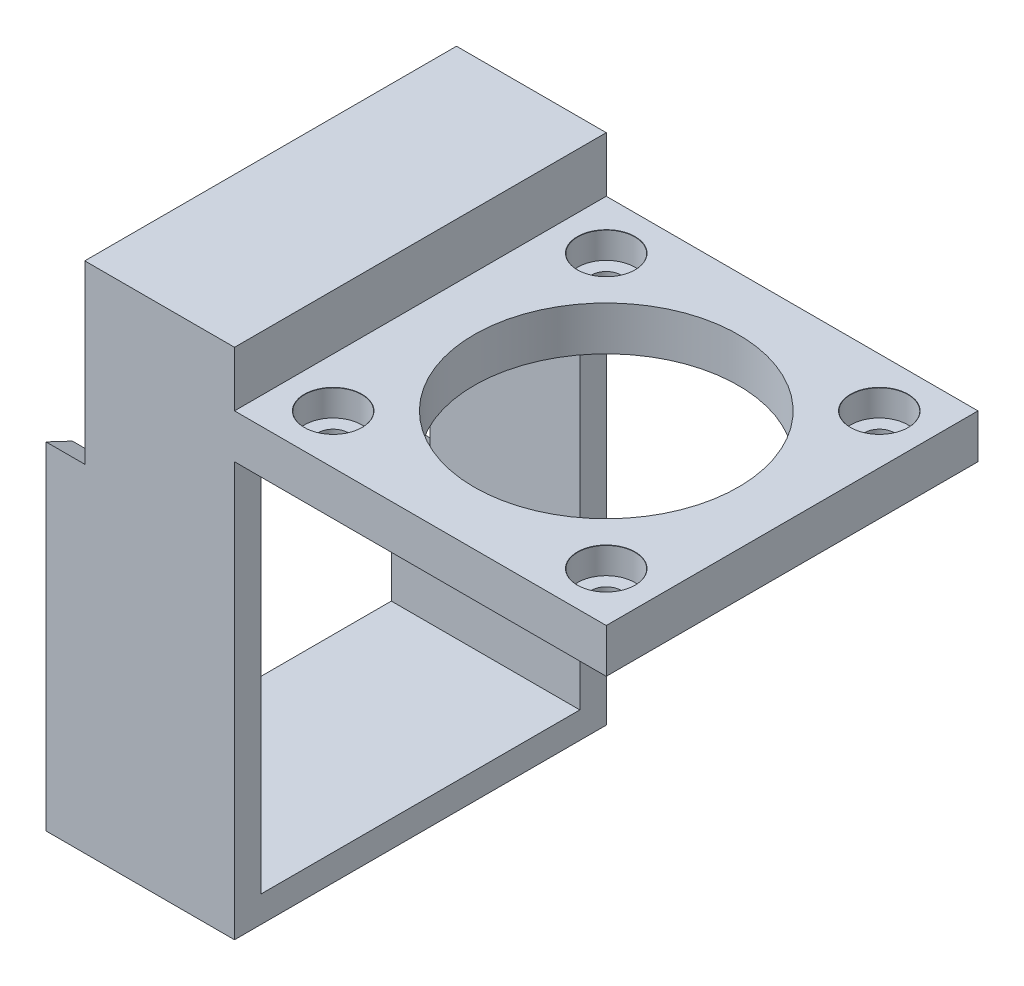
from build123d import *

# Parameters (mm, degrees)
SKETCH1_W                     = 42.2
SKETCH1_H                     = 58.25
BOSS_EXTRUDE1_DEPTH           = 17
SKETCH2_W                     = 42.2
SKETCH2_H                     = 5
BOSS_EXTRUDE2_DEPTH           = 42.2
CBORE_FOR_M3_SHCS1_AT_2_COUNT = 2
CBORE_FOR_M3_SHCS1_AT_2_PITCH = 31
CBORE_FOR_M3_SHCS1_AT_3_COUNT = 2
CBORE_FOR_M3_SHCS1_AT_3_PITCH = 43.840620434
CBORE_FOR_M3_SHCS1_AT_4_COUNT = 2
CBORE_FOR_M3_SHCS1_AT_4_PITCH = 31
SKETCH5_R                     = 15
CUT_EXTRUDE1_DEPTH            = 53
BOSS_EXTRUDE3_DEPTH           = 4.4
SKETCH7_W                     = 36.2
SKETCH7_H                     = 41.25
CUT_EXTRUDE2_DEPTH            = 22.4


with BuildPart() as part:
    # Sketch1 → Boss-Extrude1 (new body)
    with BuildSketch(Plane(origin=(0, 0, 0), x_dir=(0, 0, -1), z_dir=(1, 0, 0))):
        with Locations((0, 29.125)):
            Rectangle(SKETCH1_W, SKETCH1_H)
    extrude(amount=BOSS_EXTRUDE1_DEPTH)

    # Sketch2 → Boss-Extrude2 (add)
    with BuildSketch(Plane(origin=(17, 0, 0), x_dir=(0, 0, -1), z_dir=(1, 0, 0))):
        with Locations((0, 49.5)):
            Rectangle(SKETCH2_W, SKETCH2_H)
    extrude(amount=BOSS_EXTRUDE2_DEPTH)

    # Sketch4 → CBORE for M3 SHCS1 (revolve, cut)
    with BuildSketch(Plane(origin=(53.6, 52, 15.5), x_dir=(0, 0, 1), z_dir=(1, 0, 0))):
        Polygon((0, 0), (0, 52), (1.7, 52), (1.7, 3), (3.25, 3), (3.25, 0.025), (3.275, 0), align=None)
    cbore_for_m3_shcs1 = revolve(axis=Axis((53.6, 58.35, 15.5), (0, -1, 0)), mode=Mode.SUBTRACT)

    # CBORE for M3 SHCS1 at 2: CBORE for M3 SHCS1 ×2
    with Locations(*[(0, 0, -i * CBORE_FOR_M3_SHCS1_AT_2_PITCH) for i in range(1, CBORE_FOR_M3_SHCS1_AT_2_COUNT)]):
        add(cbore_for_m3_shcs1, mode=Mode.SUBTRACT)

    # CBORE for M3 SHCS1 at 3: CBORE for M3 SHCS1 ×2
    with Locations(*[Vector(-0.707106781, 0, -0.707106781) * (i * CBORE_FOR_M3_SHCS1_AT_3_PITCH) for i in range(1, CBORE_FOR_M3_SHCS1_AT_3_COUNT)]):
        add(cbore_for_m3_shcs1, mode=Mode.SUBTRACT)

    # CBORE for M3 SHCS1 at 4: CBORE for M3 SHCS1 ×2
    with Locations(*[(-i * CBORE_FOR_M3_SHCS1_AT_4_PITCH, 0, 0) for i in range(1, CBORE_FOR_M3_SHCS1_AT_4_COUNT)]):
        add(cbore_for_m3_shcs1, mode=Mode.SUBTRACT)

    # Sketch5 → Cut-Extrude1 (cut, through all)
    with BuildSketch(Plane(origin=(0, 52, 0), x_dir=(1, 0, 0), z_dir=(0, 1, 0))):
        with Locations((38.1, 0)):
            Circle(SKETCH5_R)
    extrude(amount=-CUT_EXTRUDE1_DEPTH, mode=Mode.SUBTRACT)

    # Sketch6 → Boss-Extrude3 (add)
    with BuildSketch(Plane(origin=(0, 0, 0), x_dir=(0, 0, -1), z_dir=(1, 0, 0))):
        Polygon((-21.1, 38.25), (21.1, 18.25), (21.1, 0), (-21.1, 0), align=None)
    extrude(amount=-BOSS_EXTRUDE3_DEPTH)

    # Sketch7 → Cut-Extrude2 (cut, through all)
    with BuildSketch(Plane(origin=(17, 0, 0), x_dir=(0, 0, -1), z_dir=(1, 0, 0))):
        with Locations((0, 23.625)):
            Rectangle(SKETCH7_W, SKETCH7_H)
    extrude(amount=-CUT_EXTRUDE2_DEPTH, mode=Mode.SUBTRACT)


solid = part.part
